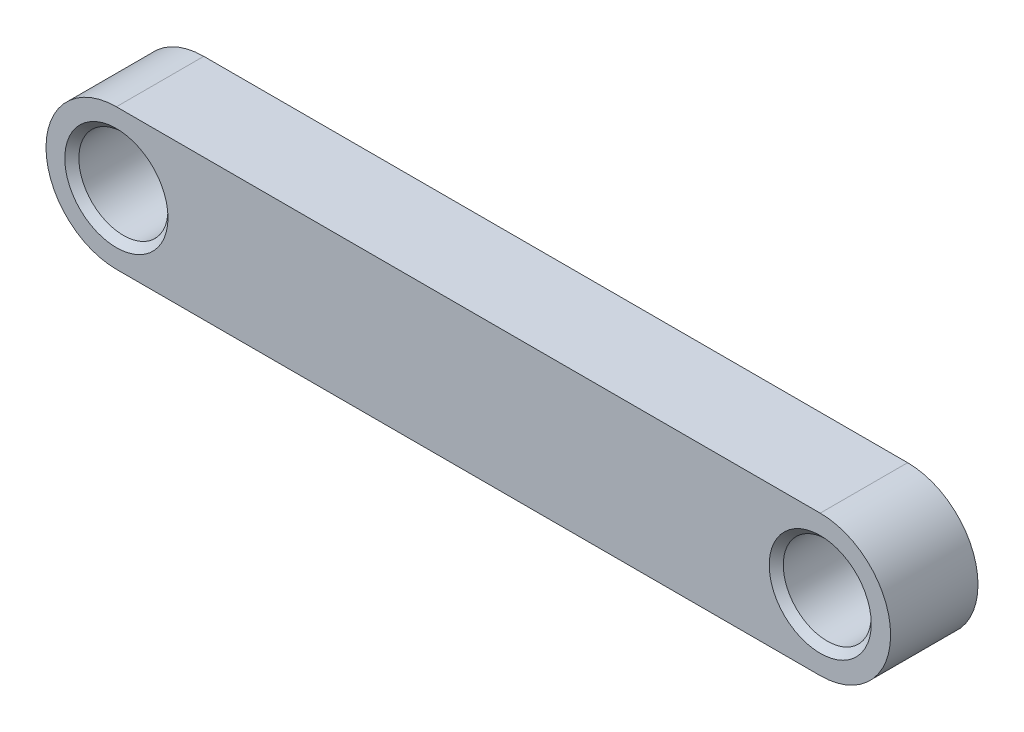
from build123d import *

# Parameters (mm, degrees)
BOSS_EXTRUDE1_DEPTH = 9.4615
SKETCH2_R           = 4.7625
SKETCH2_R_2         = 4.826
CUT_EXTRUDE1_DEPTH  = 10.4615
CHAMFER1_SIZE       = 0.762


with BuildPart() as part:
    # Sketch1 → Boss-Extrude1 (new body)
    with BuildSketch(Plane.XY):
        with BuildLine():
            Line((-38.1, 7.62), (38.1, 7.62))
            ThreePointArc((38.1, 7.62), (45.72, 0), (38.1, -7.62))
            Line((38.1, -7.62), (-38.1, -7.62))
            ThreePointArc((-38.1, -7.62), (-45.72, 0), (-38.1, 7.62))
        make_face()
    extrude(amount=BOSS_EXTRUDE1_DEPTH)

    # Sketch2 → Cut-Extrude1 (cut, through all)
    with BuildSketch(Plane.XY.offset(9.4615)):
        with Locations((38.1, 0)):
            Circle(SKETCH2_R)
        with Locations((-38.1, 0)):
            Circle(SKETCH2_R_2)
    extrude(amount=-CUT_EXTRUDE1_DEPTH, mode=Mode.SUBTRACT)

    # Chamfer1
    chamfer1_edges = [part.edges().sort_by_distance(p)[0] for p in [
        (33.3375, 0, 0),
        (33.3375, 0, 9.4615),
        (-42.926, 0, 0),
        (-42.926, 0, 9.4615),
    ]]
    chamfer(chamfer1_edges, length=CHAMFER1_SIZE)


solid = part.part
